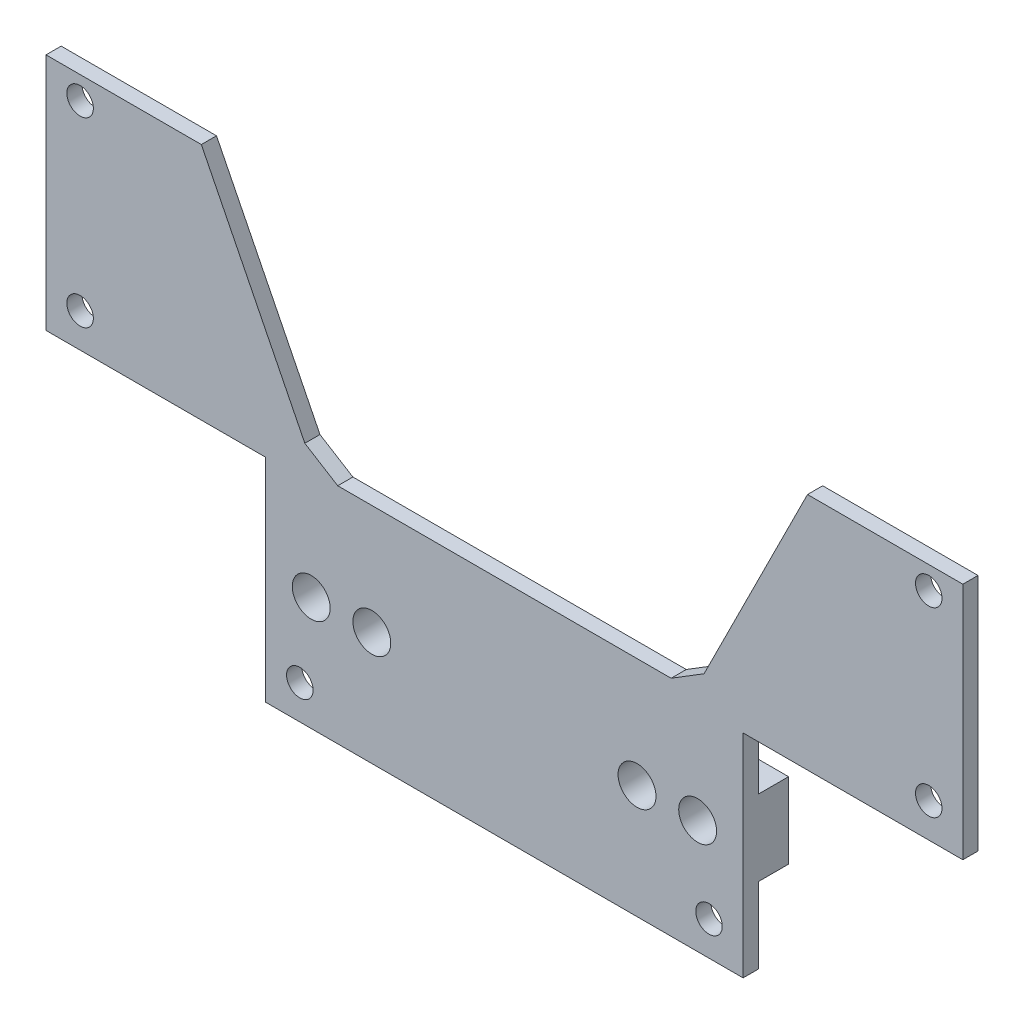
from build123d import *

# Parameters (mm, degrees)
P_IDAT_VYSUNUT_M1_DEPTH  = 2
SKICA2_R                 = 1.75
ODEBRAT_VYSUNUT_M1_DEPTH = 10
SKICA3_W                 = 63
SKICA3_H                 = 10
P_IDAT_VYSUNUT_M2_DEPTH  = 4
SKICA4_R                 = 2.5
ODEBRAT_VYSUNUT_M2_DEPTH = 24
ODEBRAT_VYSUNUT_M3_DEPTH = 10
P_IDAT_VYSUNUT_M3_DEPTH  = 2


with BuildPart() as part:
    # Skica1 → Přidat vysunutím1 (new body)
    with BuildSketch(Plane.XY):
        Polygon((-31.5, 0), (31.5, 0), (31.5, 28), (60.5, 28), (60.5, 59.5), (-60.5, 59.5), (-60.5, 28), (-31.5, 28), align=None)
    extrude(amount=P_IDAT_VYSUNUT_M1_DEPTH)

    # Skica2 → Odebrat vysunutím1 (cut)
    with BuildSketch(Plane(origin=(0, 0, 0), x_dir=(-1, 0, 0), z_dir=(0, 0, -1))):
        with Locations((-56, 56.5)):
            Circle(SKICA2_R)
        with Locations((-56, 32.5)):
            Circle(SKICA2_R)
        with Locations((-27, 4.5)):
            Circle(SKICA2_R)
        with Locations((27, 4.5)):
            Circle(SKICA2_R)
        with Locations((56, 32.5)):
            Circle(SKICA2_R)
        with Locations((56, 56.5)):
            Circle(SKICA2_R)
    extrude(amount=-ODEBRAT_VYSUNUT_M1_DEPTH, mode=Mode.SUBTRACT)

    # Skica3 → Přidat vysunutím2 (add)
    with BuildSketch(Plane.XY):
        with Locations((0, 15)):
            Rectangle(SKICA3_W, SKICA3_H)
    extrude(amount=-P_IDAT_VYSUNUT_M2_DEPTH)

    # Skica4 → Odebrat vysunutím2 (cut)
    with BuildSketch(Plane(origin=(0, 0, -4), x_dir=(-1, 0, 0), z_dir=(0, 0, -1))):
        with Locations((17.5, 15)):
            Circle(SKICA4_R)
        with Locations((25.5, 15)):
            Circle(SKICA4_R)
        with Locations((-25.5, 15)):
            Circle(SKICA4_R)
        with Locations((-17.5, 15)):
            Circle(SKICA4_R)
    extrude(amount=-ODEBRAT_VYSUNUT_M2_DEPTH, mode=Mode.SUBTRACT)

    # Skica5 → Odebrat vysunutím3 (cut)
    with BuildSketch(Plane.XY.offset(2)):
        Polygon((40, 59.5), (-40, 59.5), (-25, 29.5), (25, 29.5), align=None)
    extrude(amount=-ODEBRAT_VYSUNUT_M3_DEPTH, mode=Mode.SUBTRACT)

    # Skica6 → Přidat vysunutím3 (add)
    with BuildSketch(Plane(origin=(0, 0, 0), x_dir=(-1, 0, 0), z_dir=(0, 0, -1))):
        Polygon((-25, 29.5), (-26.341640786, 32.183281573), (-22, 29.5), align=None)
        Polygon((25, 29.5), (26.341640786, 32.183281573), (22, 29.5), align=None)
    extrude(amount=-P_IDAT_VYSUNUT_M3_DEPTH)


solid = part.part
